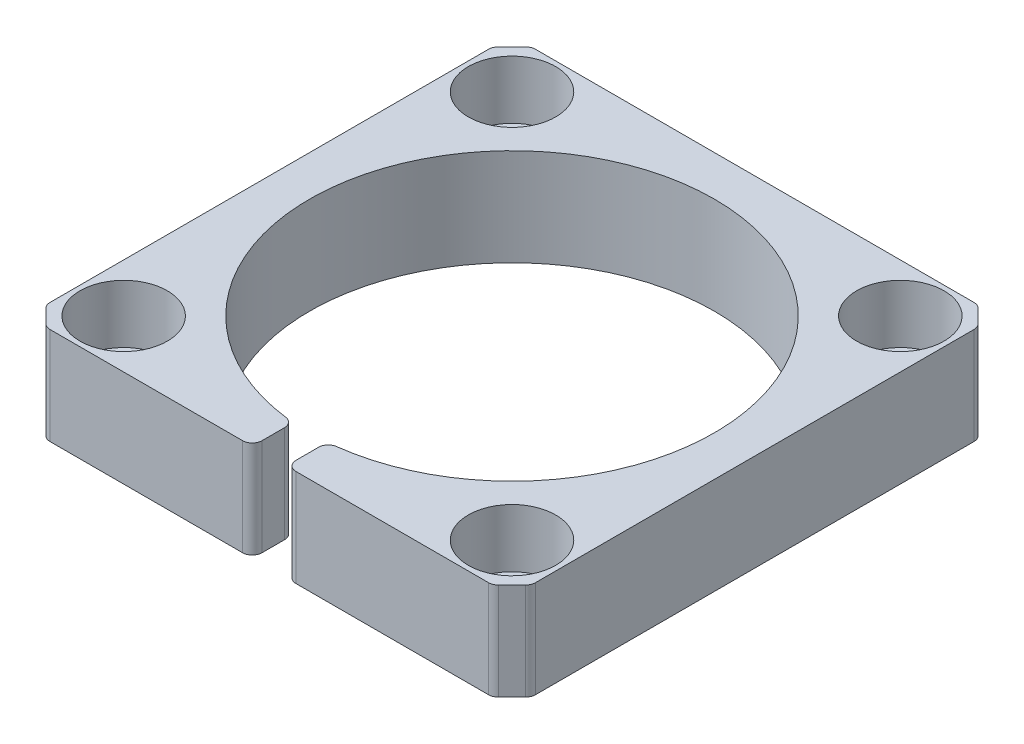
from build123d import *

# Parameters (mm, degrees)
SKETCH1_W                                           = 50
SKETCH1_H                                           = 50
SKETCH1_R                                           = 20.85
BOSS_EXTRUDE1_DEPTH                                 = 10
SKETCH2_W                                           = 3.5
SKETCH2_H                                           = 12.12353247
CUT_EXTRUDE1_DEPTH                                  = 10
CHAMFER1_SIZE                                       = 2
FILLET1_R                                           = 1
F_5_2_5_2_DIAMETER_HOLE1_D                          = 5.2
F_5_2_5_2_DIAMETER_HOLE1_DEPTH                      = 10
F_5_2_5_2_DIAMETER_HOLE1_TIP                        = 1.562237609
CBORE_FOR_M5_HEX_SOCKET_HEAD_CAP_SCREW1_D           = 5.5
CBORE_FOR_M5_HEX_SOCKET_HEAD_CAP_SCREW1_CBORE_D     = 9
CBORE_FOR_M5_HEX_SOCKET_HEAD_CAP_SCREW1_CBORE_DEPTH = 6


with BuildPart() as part:
    # Sketch1 → Boss-Extrude1 (new body)
    with BuildSketch(Plane(origin=(0, 0, 0), x_dir=(1, 0, 0), z_dir=(0, 1, 0))):
        Rectangle(SKETCH1_W, SKETCH1_H)
        Circle(SKETCH1_R, mode=Mode.SUBTRACT)
    extrude(amount=BOSS_EXTRUDE1_DEPTH)

    # Sketch2 → Cut-Extrude1 (cut)
    with BuildSketch(Plane(origin=(0, 10, 0), x_dir=(1, 0, 0), z_dir=(0, 1, 0))):
        with Locations((0, -25)):
            Rectangle(SKETCH2_W, SKETCH2_H)
    extrude(amount=-CUT_EXTRUDE1_DEPTH, mode=Mode.SUBTRACT)

    # Chamfer1
    chamfer1_edges = [part.edges().sort_by_distance(p)[0] for p in [
        (25, 5, 25),
        (-25, 5, 25),
        (-25, 5, -25),
        (25, 5, -25),
    ]]
    chamfer(chamfer1_edges, length=CHAMFER1_SIZE)

    # Fillet1
    fillet1_edges = [part.edges().sort_by_distance(p)[0] for p in [
        (-1.75, 5, 20.776428952),
        (1.75, 5, 20.776428952),
        (1.75, 5, 25),
        (-1.75, 5, 25),
        (-25, 5, 23),
        (-25, 5, -23),
        (23, 5, -25),
        (-23, 5, -25),
        (-23, 5, 25),
        (25, 5, 23),
        (25, 5, -23),
        (23, 5, 25),
    ]]
    fillet(fillet1_edges, radius=FILLET1_R)

    # Ø5.2 (5.2) Diameter Hole1
    with Locations(Plane(origin=(-20, 10, -20), x_dir=(0, 0, 1), z_dir=(0, 1, 0))):
        with Locations((0, 0), (0, 40), (40, 40), (40, 0)):
            Hole(F_5_2_5_2_DIAMETER_HOLE1_D / 2, depth=F_5_2_5_2_DIAMETER_HOLE1_DEPTH)
            with Locations((0, 0, -(F_5_2_5_2_DIAMETER_HOLE1_DEPTH + F_5_2_5_2_DIAMETER_HOLE1_TIP / 2))):  # 118° drill point
                Cone(0, F_5_2_5_2_DIAMETER_HOLE1_D / 2, F_5_2_5_2_DIAMETER_HOLE1_TIP, mode=Mode.SUBTRACT)

    # CBORE for M5 Hex Socket Head Cap Screw1 (through all)
    with Locations(Plane(origin=(-20, 10, -20), x_dir=(0, 0, 1), z_dir=(0, 1, 0))):
        with Locations((0, 0), (40, 0), (40, 40), (0, 40)):
            CounterBoreHole(CBORE_FOR_M5_HEX_SOCKET_HEAD_CAP_SCREW1_D / 2, CBORE_FOR_M5_HEX_SOCKET_HEAD_CAP_SCREW1_CBORE_D / 2, CBORE_FOR_M5_HEX_SOCKET_HEAD_CAP_SCREW1_CBORE_DEPTH)


solid = part.part
